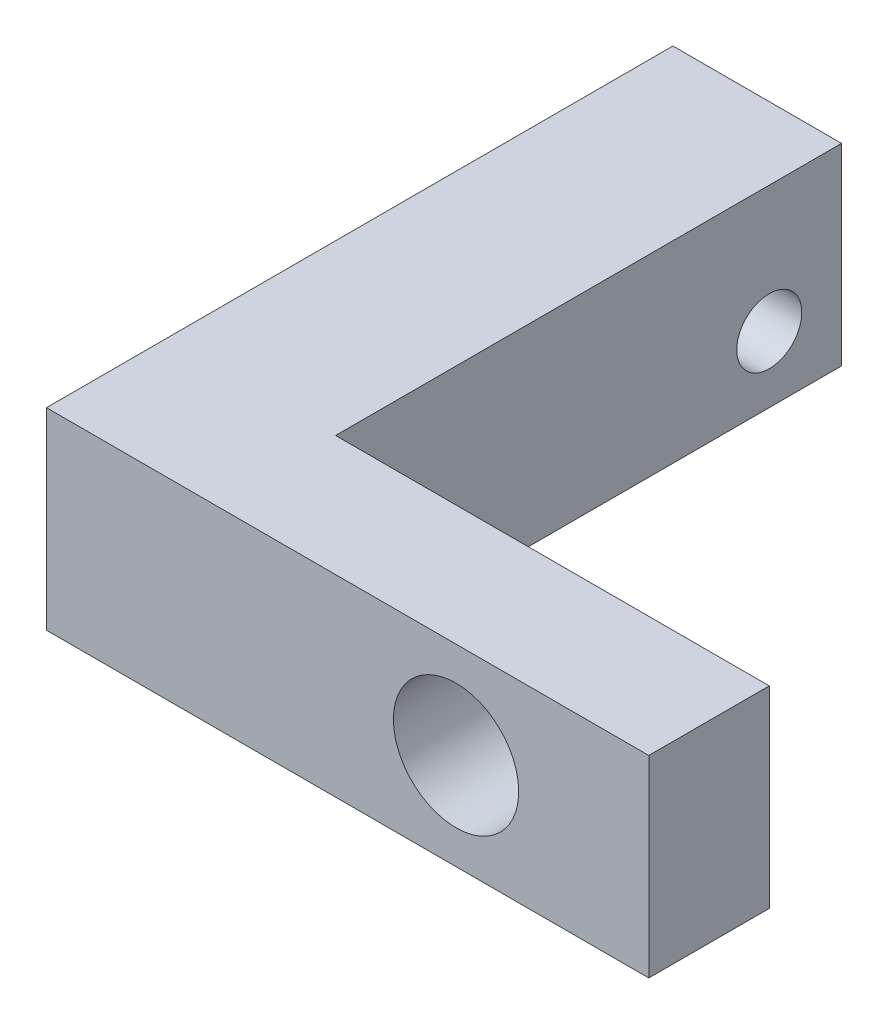
from build123d import *

# Parameters (mm, degrees)
BOSS_EXTRUDE1_DEPTH = 8
SKETCH2_R           = 1.35
CUT_EXTRUDE1_DEPTH  = 10
CUT_EXTRUDE2_REACH  = 7
SKETCH4_R           = 2.6


with BuildPart() as part:
    # Sketch1 → Boss-Extrude1 (new body)
    with BuildSketch(Plane(origin=(0, 0, 0), x_dir=(1, 0, 0), z_dir=(0, 1, 0))):
        Polygon((0, 0), (0, 26), (7, 26), (7, 5), (25, 5), (25, 0), align=None)
    extrude(amount=BOSS_EXTRUDE1_DEPTH)

    # Sketch2 → Cut-Extrude1 (cut)
    with BuildSketch(Plane.ZY):
        with Locations((-23, 2.75)):
            Circle(SKETCH2_R)
        with Locations((-3.5, 2.75)):
            Circle(SKETCH2_R)
    extrude(amount=-CUT_EXTRUDE1_DEPTH, mode=Mode.SUBTRACT)

    # Sketch4 → Cut-Extrude2 (cut, up to next)
    with BuildSketch(Plane(origin=(0, 0, -5), x_dir=(-1, 0, 0), z_dir=(0, 0, -1)), mode=Mode.PRIVATE) as cut_extrude2_sk1:
        with Locations((-17, 4)):
            Circle(SKETCH4_R)
    cut_extrude2_tool1 = extrude(cut_extrude2_sk1.sketch, amount=-CUT_EXTRUDE2_REACH, mode=Mode.PRIVATE) & part.part
    add(cut_extrude2_tool1.solids().sort_by_distance((17, 4, -5))[0], mode=Mode.SUBTRACT)


solid = part.part
